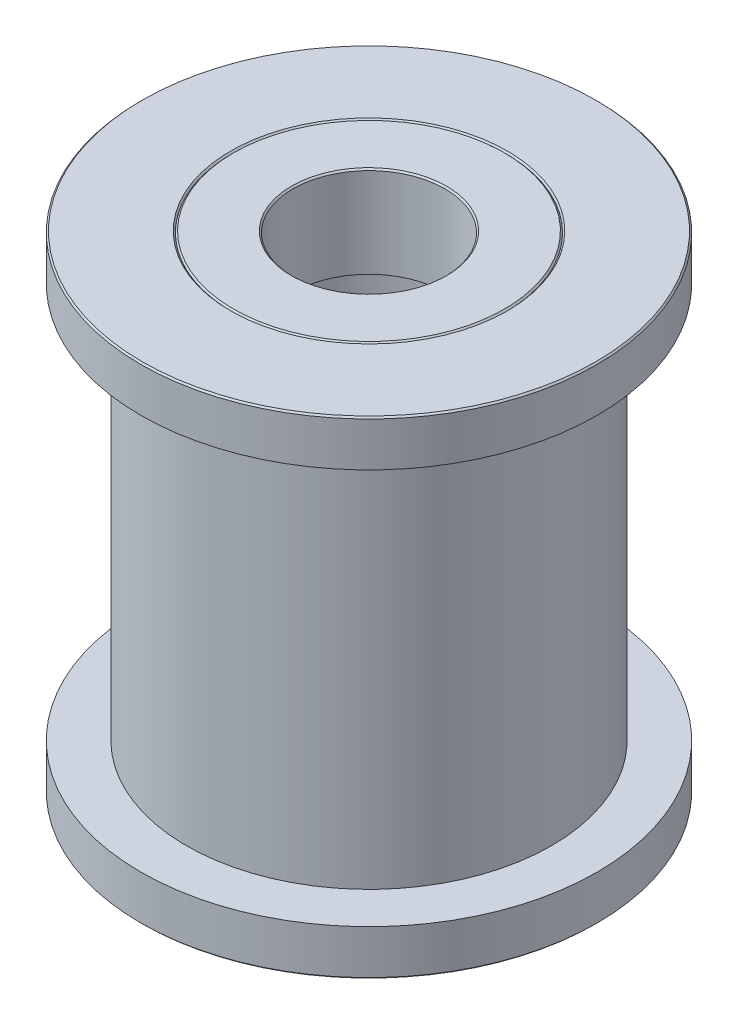
from build123d import *

# Parameters (mm, degrees)
CHAMFER1_SIZE = 0.05
SKETCH1_3_W   = 2
SKETCH1_3_H   = 3
CHAMFER2_SIZE = 0.05
CHAMFER3_SIZE = 0.05


with BuildPart() as part:
    # Sketch1 → Revolve1 (revolve)
    with BuildSketch(Plane.XY):
        Polygon((6, -7.075803982), (6, 5.924196018), (7.5, 5.924196018), (7.5, 7.424196018), (4.5, 7.424196018), (4.5, 4.424196018), (3.5, 4.424196018), (3.5, -5.575803982), (4.5, -5.575803982), (4.5, -8.575803982), (7.5, -8.575803982), (7.5, -7.075803982), align=None)
    revolve(axis=Axis((0, -12.88820827, 0), (0, 1, 0)))

    # Chamfer1
    chamfer1_edges = [part.edges().sort_by_distance(p)[0] for p in [
        (-4.5, -8.575803982, 0),
        (-4.5, 7.424196018, 0),
        (-7.5, 7.424196018, 0),
        (-7.5, -8.575803982, 0),
    ]]
    chamfer(chamfer1_edges, length=CHAMFER1_SIZE)


with BuildPart() as body_2:
    # Sketch1_3 → Revolve2 (revolve)
    with BuildSketch(Plane.XY):
        with Locations((3.5, 5.924196018)):
            Rectangle(SKETCH1_3_W, SKETCH1_3_H)
        with Locations((3.5, -7.075803982)):
            Rectangle(SKETCH1_3_W, SKETCH1_3_H)
    revolve(axis=Axis((0, -12.88820827, 0), (0, 1, 0)))

    # Chamfer2
    chamfer2_edges = [body_2.edges().sort_by_distance(p)[0] for p in [
        (-4.5, -8.575803982, 0),
        (-2.5, -8.575803982, 0),
    ]]
    chamfer(chamfer2_edges, length=CHAMFER2_SIZE)

    # Chamfer3
    chamfer3_edges = [body_2.edges().sort_by_distance(p)[0] for p in [
        (-4.5, 7.424196018, 0),
        (-2.5, 7.424196018, 0),
    ]]
    chamfer(chamfer3_edges, length=CHAMFER3_SIZE)


solid = Compound([part.part, body_2.part])
